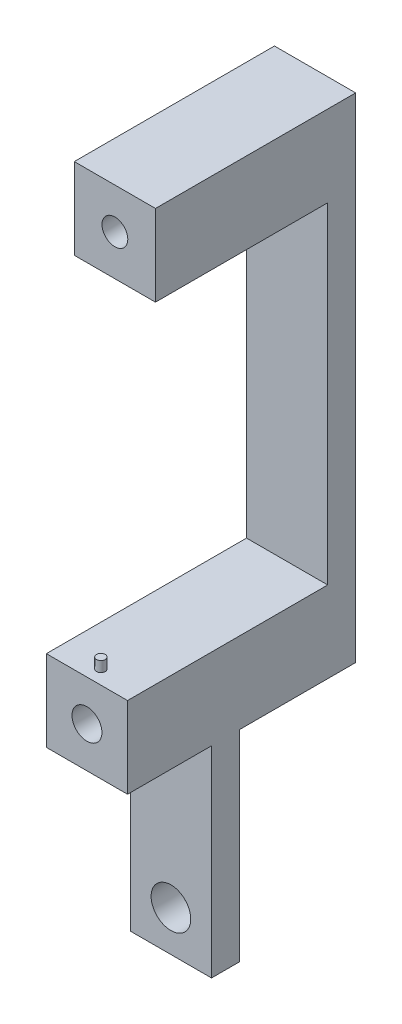
from build123d import *

# Parameters (mm, degrees)
SKETCH1_W           = 13.843
SKETCH1_H           = 48.133
BOSS_EXTRUDE1_DEPTH = 4.7625
SKETCH2_R           = 3.3782
CUT_EXTRUDE1_DEPTH  = 5.7625
SKETCH3_W           = 13.843
SKETCH3_H           = 13.843
BOSS_EXTRUDE2_DEPTH = 14.31925
SKETCH6_W           = 13.843
SKETCH6_H           = 13.843
BOSS_EXTRUDE3_DEPTH = 19.812
SKETCH4_R           = 2.5527
CUT_EXTRUDE2_DEPTH  = 27.01925
SKETCH7_R           = 4.8641
CUT_EXTRUDE3_DEPTH  = 19.812
SKETCH8_W           = 13.843
SKETCH8_H           = 4.7625
BOSS_EXTRUDE4_DEPTH = 70.2818
SKETCH9_W           = 13.843
SKETCH9_H           = 13.843
BOSS_EXTRUDE5_DEPTH = 29.36875
SKETCH10_R          = 4.1275
CUT_EXTRUDE4_DEPTH  = 7.62
SKETCH11_R          = 2.2
CUT_EXTRUDE5_DEPTH  = 32.27375
SKETCH12_R          = 0.7493
BOSS_EXTRUDE6_DEPTH = 1.778


with BuildPart() as part:
    # Sketch1 → Boss-Extrude1 (new body)
    with BuildSketch(Plane.XY):
        with Locations((6.9215, 24.0665)):
            Rectangle(SKETCH1_W, SKETCH1_H)
    extrude(amount=BOSS_EXTRUDE1_DEPTH)

    # Sketch2 → Cut-Extrude1 (cut, through all)
    with BuildSketch(Plane(origin=(0, 0, 0), x_dir=(-1, 0, 0), z_dir=(0, 0, -1))):
        with Locations((-6.9215, 6.9215)):
            Circle(SKETCH2_R)
    extrude(amount=-CUT_EXTRUDE1_DEPTH, mode=Mode.SUBTRACT)

    # Sketch3 → Boss-Extrude2 (add)
    with BuildSketch(Plane.XY.offset(4.7625)):
        with Locations((6.9215, 41.2115)):
            Rectangle(SKETCH3_W, SKETCH3_H)
    extrude(amount=BOSS_EXTRUDE2_DEPTH)

    # Sketch6 → Boss-Extrude3 (add)
    with BuildSketch(Plane(origin=(0, 0, 0), x_dir=(-1, 0, 0), z_dir=(0, 0, -1))):
        with Locations((-6.9215, 41.2115)):
            Rectangle(SKETCH6_W, SKETCH6_H)
    extrude(amount=BOSS_EXTRUDE3_DEPTH)

    # Sketch4 → Cut-Extrude2 (cut)
    with BuildSketch(Plane(origin=(0, 0, 0), x_dir=(-1, 0, 0), z_dir=(0, 0, -1))):
        with Locations((-6.9215, 41.2115)):
            Circle(SKETCH4_R)
    extrude(amount=-CUT_EXTRUDE2_DEPTH, mode=Mode.SUBTRACT)

    # Sketch7 → Cut-Extrude3 (cut)
    with BuildSketch(Plane(origin=(0, 0, -19.812), x_dir=(-1, 0, 0), z_dir=(0, 0, -1))):
        with Locations((-6.9215, 41.2115)):
            Circle(SKETCH7_R)
    extrude(amount=-CUT_EXTRUDE3_DEPTH, mode=Mode.SUBTRACT)

    # Sketch8 → Boss-Extrude4 (add)
    with BuildSketch(Plane(origin=(0, 48.133, 0), x_dir=(1, 0, 0), z_dir=(0, 1, 0))):
        with Locations((6.9215, 17.43075)):
            Rectangle(SKETCH8_W, SKETCH8_H)
    extrude(amount=BOSS_EXTRUDE4_DEPTH)

    # Sketch9 → Boss-Extrude5 (add)
    with BuildSketch(Plane.XY.offset(-15.0495)):
        with Locations((6.9215, 111.4933)):
            Rectangle(SKETCH9_W, SKETCH9_H)
    extrude(amount=BOSS_EXTRUDE5_DEPTH)

    # Sketch10 → Cut-Extrude4 (cut)
    with BuildSketch(Plane(origin=(0, 0, -19.812), x_dir=(-1, 0, 0), z_dir=(0, 0, -1))):
        with Locations((-6.9215, 111.4933)):
            Circle(SKETCH10_R)
    extrude(amount=-CUT_EXTRUDE4_DEPTH, mode=Mode.SUBTRACT)

    # Sketch11 → Cut-Extrude5 (cut, through all)
    with BuildSketch(Plane(origin=(0, 0, -12.192), x_dir=(-1, 0, 0), z_dir=(0, 0, -1))):
        with Locations((-6.9215, 111.4933)):
            Circle(SKETCH11_R)
    extrude(amount=-CUT_EXTRUDE5_DEPTH, mode=Mode.SUBTRACT)

    # Sketch12 → Boss-Extrude6 (add)
    with BuildSketch(Plane(origin=(0, 48.133, 0), x_dir=(1, 0, 0), z_dir=(0, 1, 0))):
        with Locations((6.9215, -16.7005)):
            Circle(SKETCH12_R)
    extrude(amount=BOSS_EXTRUDE6_DEPTH)


solid = part.part
